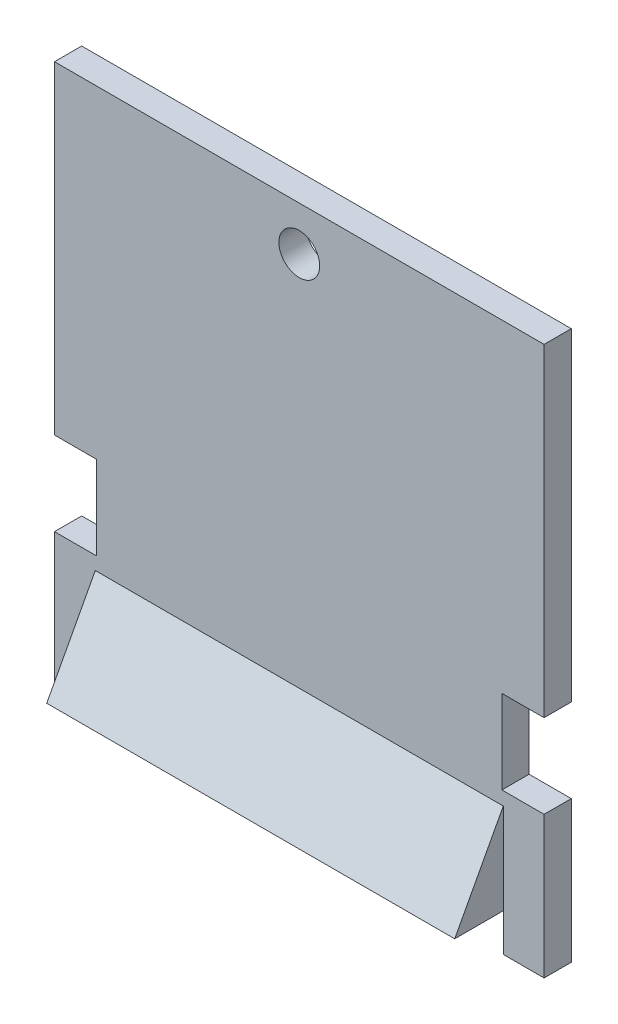
from build123d import *

# Parameters (mm, degrees)
BOSS_EXTRUDE1_DEPTH = 18
SKETCH2_R           = 1.5
SKETCH2_W           = 30
SKETCH2_H           = 2.78
CUT_EXTRUDE1_DEPTH  = 6.57
SKETCH3_W           = 3.1
SKETCH3_H           = 6.15
CUT_EXTRUDE2_DEPTH  = 6.57
SKETCH4_W           = 3
SKETCH4_H           = 7.645
CUT_EXTRUDE3_DEPTH  = 4.57


with BuildPart() as part:
    # Sketch1 → Boss-Extrude1 (new body, symmetric)
    with BuildSketch(Plane(origin=(0, 0, 0), x_dir=(0, 0, -1), z_dir=(1, 0, 0))):
        Polygon((0, 0), (0, 40.35), (-2, 40.35), (-2, 9.45), (-5.57, 2.78), (-2, 2.78), (-2, 0), align=None)
    extrude(amount=BOSS_EXTRUDE1_DEPTH, both=True)

    # Sketch2 → Cut-Extrude1 (cut, through all)
    with BuildSketch(Plane(origin=(0, 0, 0), x_dir=(-1, 0, 0), z_dir=(0, 0, -1))):
        with Locations((0, 37.1)):
            Circle(SKETCH2_R)
        with Locations((0, 1.39)):
            Rectangle(SKETCH2_W, SKETCH2_H)
    extrude(amount=-CUT_EXTRUDE1_DEPTH, mode=Mode.SUBTRACT)

    # Sketch3 → Cut-Extrude2 (cut, through all)
    with BuildSketch(Plane(origin=(0, 0, 0), x_dir=(-1, 0, 0), z_dir=(0, 0, -1))):
        with Locations((-16.45, 13.5)):
            Rectangle(SKETCH3_W, SKETCH3_H)
        with Locations((16.45, 13.5)):
            Rectangle(SKETCH3_W, SKETCH3_H)
    extrude(amount=-CUT_EXTRUDE2_DEPTH, mode=Mode.SUBTRACT)

    # Sketch4 → Cut-Extrude3 (cut, through all)
    with BuildSketch(Plane.XY.offset(2)):
        with Locations((-16.5, 6.6025)):
            Rectangle(SKETCH4_W, SKETCH4_H)
        with Locations((16.5, 6.6025)):
            Rectangle(SKETCH4_W, SKETCH4_H)
    extrude(amount=CUT_EXTRUDE3_DEPTH, mode=Mode.SUBTRACT)


solid = part.part
